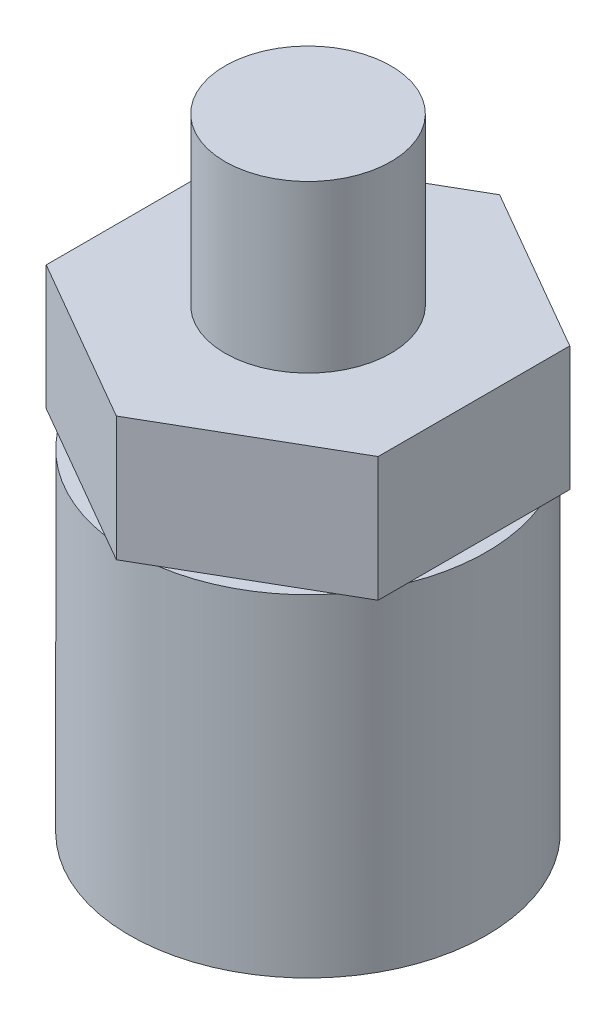
from build123d import *

# Parameters (mm, degrees)
BOSS_EXTRUDE1_DEPTH = 3
SKETCH2_R           = 4.3
BOSS_EXTRUDE2_DEPTH = 8
SKETCH3_R           = 2
BOSS_EXTRUDE3_DEPTH = 4


with BuildPart() as part:
    # Sketch1 → Boss-Extrude1 (new body)
    with BuildSketch(Plane(origin=(0, 0, 0), x_dir=(1, 0, 0), z_dir=(0, 1, 0))):
        Polygon((0, -4.618802154), (4, -2.309401077), (4, 2.309401077), (0, 4.618802154), (-4, 2.309401077), (-4, -2.309401077), align=None)
    extrude(amount=BOSS_EXTRUDE1_DEPTH)

    # Sketch2 → Boss-Extrude2 (add)
    with BuildSketch(Plane.XZ):
        Circle(SKETCH2_R)
    extrude(amount=BOSS_EXTRUDE2_DEPTH)

    # Sketch3 → Boss-Extrude3 (add)
    with BuildSketch(Plane(origin=(0, 3, 0), x_dir=(1, 0, 0), z_dir=(0, 1, 0))):
        Circle(SKETCH3_R)
    extrude(amount=BOSS_EXTRUDE3_DEPTH)


solid = part.part
